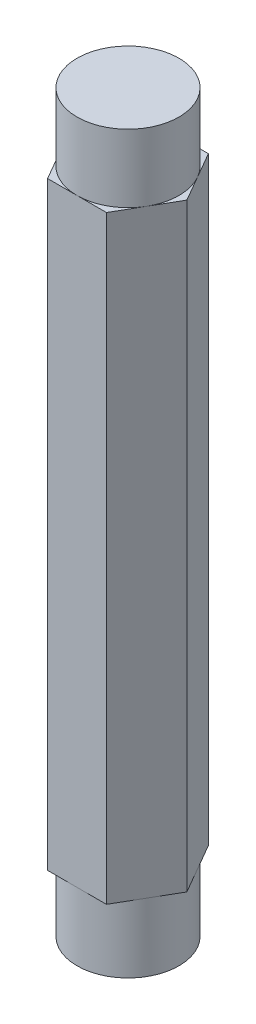
from build123d import *

# Parameters (mm, degrees)
BOSS_EXTRUDE1_DEPTH = 13.9954
SKETCH2_R           = 2.38125
BOSS_EXTRUDE2_DEPTH = 3.175


with BuildPart() as part:
    # Sketch1 → Boss-Extrude1 (new body, symmetric)
    with BuildSketch(Plane(origin=(0, 0, 0), x_dir=(1, 0, 0), z_dir=(0, 1, 0))):
        Polygon((1.374815329, -2.38125), (2.749630657, 0), (1.374815329, 2.38125), (-1.374815329, 2.38125), (-2.749630657, 0), (-1.374815329, -2.38125), align=None)
    extrude(amount=BOSS_EXTRUDE1_DEPTH, both=True)

    # Sketch2 → Boss-Extrude2 (add)
    with BuildSketch(Plane(origin=(0, 13.9954, 0), x_dir=(1, 0, 0), z_dir=(0, 1, 0))):
        Circle(SKETCH2_R)
    boss_extrude2 = extrude(amount=BOSS_EXTRUDE2_DEPTH)

    # Mirror1: Boss-Extrude2 across plane
    add(boss_extrude2.mirror(Plane.ZX))


solid = part.part
